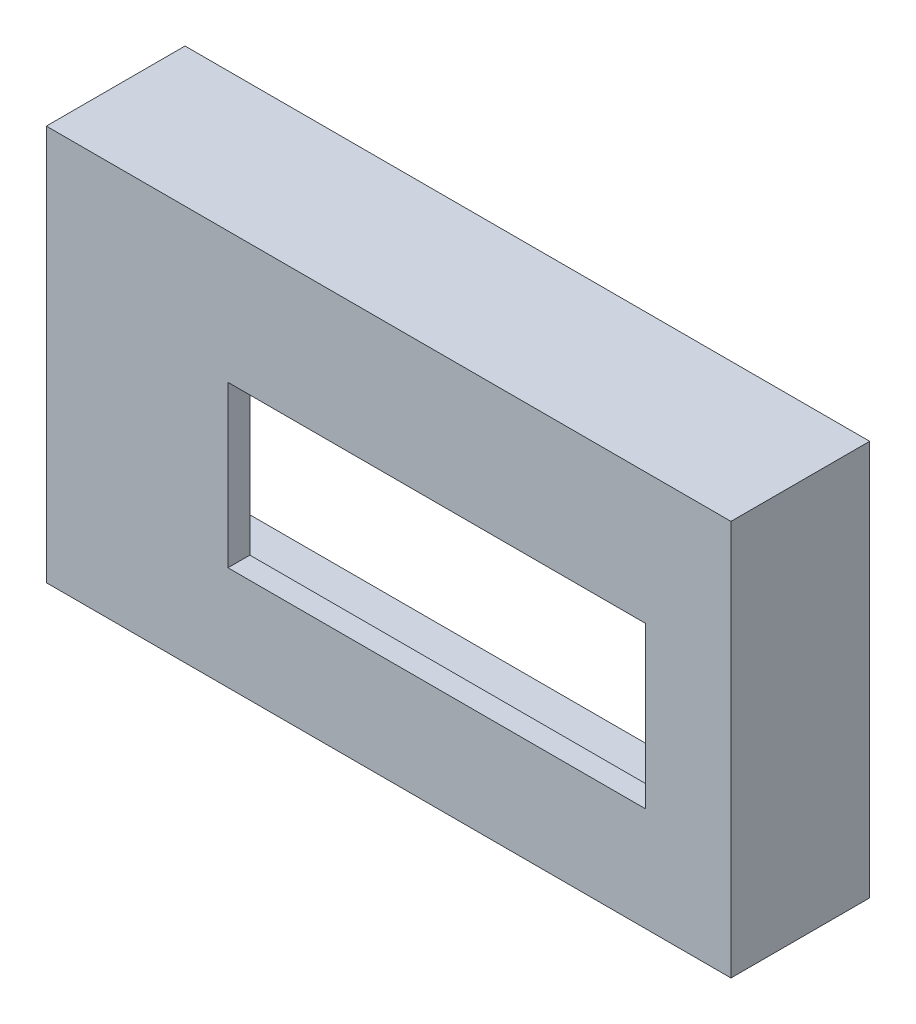
from build123d import *

# Parameters (mm, degrees)
SKETCH1_W           = 119.105009205
SKETCH1_H           = 68.796475466
SKETCH1_W_2         = 72.644
SKETCH1_H_2         = 27.94
BOSS_EXTRUDE2_DEPTH = 3.81
SKETCH2_W           = 119.105009205
SKETCH2_H           = 68.796475466
SKETCH2_W_2         = 111.485009205
SKETCH2_H_2         = 61.176475466
BOSS_EXTRUDE3_DEPTH = 20.32


with BuildPart() as part:
    # Sketch1 → Boss-Extrude2 (new body)
    with BuildSketch(Plane.XY):
        with Locations((32.019529699, 19.90260555)):
            Rectangle(SKETCH1_W, SKETCH1_H)
        with Locations((40.386, 17.526)):
            Rectangle(SKETCH1_W_2, SKETCH1_H_2, mode=Mode.SUBTRACT)
    extrude(amount=BOSS_EXTRUDE2_DEPTH)

    # Sketch2 → Boss-Extrude3 (add)
    with BuildSketch(Plane.XY):
        with Locations((32.019529699, 19.90260555)):
            Rectangle(SKETCH2_W, SKETCH2_H)
        with Locations((32.019529699, 19.90260555)):
            Rectangle(SKETCH2_W_2, SKETCH2_H_2, mode=Mode.SUBTRACT)
    extrude(amount=-BOSS_EXTRUDE3_DEPTH)


solid = part.part
